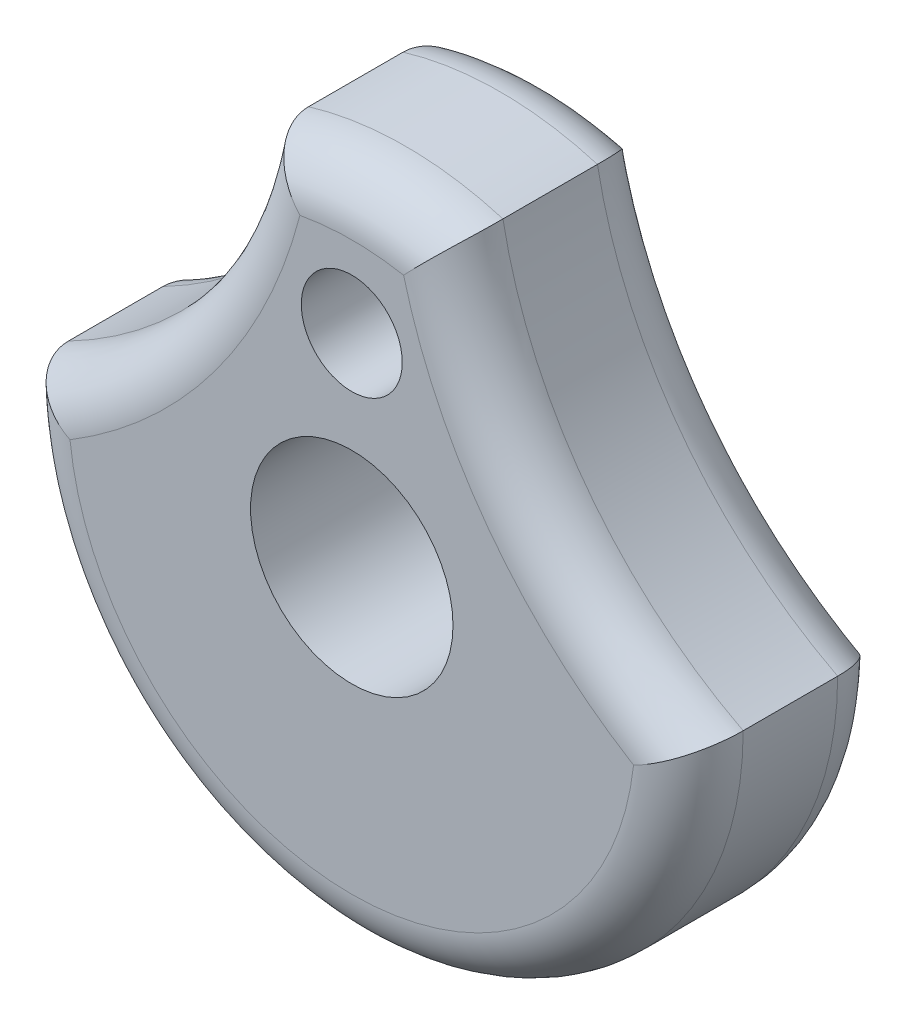
from build123d import *

# Parameters (mm, degrees)
BOSS_EXTRUDE1_DEPTH = 9.525
SKETCH2_R           = 4.7625
SKETCH2_R_2         = 2.3749
CUT_EXTRUDE1_DEPTH  = 9.525
FILLET1_R           = 2.54


with BuildPart() as part:
    # Sketch1 → Boss-Extrude1 (new body)
    with BuildSketch(Plane.XY):
        with BuildLine():
            ThreePointArc((4.57280399, 15.202140924), (0, 15.875), (-4.57280399, 15.202140924))
            ThreePointArc((-4.57280399, 15.202140924), (-8.467578202, 6.295312552), (-15.875, 0))
            ThreePointArc((-15.875, 0), (0, -15.875), (15.875, 0))
            ThreePointArc((15.875, 0), (8.467578202, 6.295312552), (4.57280399, 15.202140924))
        make_face()
    extrude(amount=BOSS_EXTRUDE1_DEPTH)

    # Sketch2 → Cut-Extrude1 (cut)
    with BuildSketch(Plane.XY.offset(9.525)):
        Circle(SKETCH2_R)
        with Locations((0, 9.525)):
            Circle(SKETCH2_R_2)
    extrude(amount=-CUT_EXTRUDE1_DEPTH, mode=Mode.SUBTRACT)

    # Fillet1
    fillet1_edges = [part.edges().sort_by_distance(p)[0] for p in [
        (-8.467578202, 6.295312552, 9.525),
        (0, -15.875, 9.525),
        (8.467578202, 6.295312552, 9.525),
        (0, -15.875, 0),
        (-8.467578202, 6.295312552, 0),
        (0, 15.875, 0),
        (8.467578202, 6.295312552, 0),
        (0, 15.875, 9.525),
    ]]
    fillet(fillet1_edges, radius=FILLET1_R)


solid = part.part
